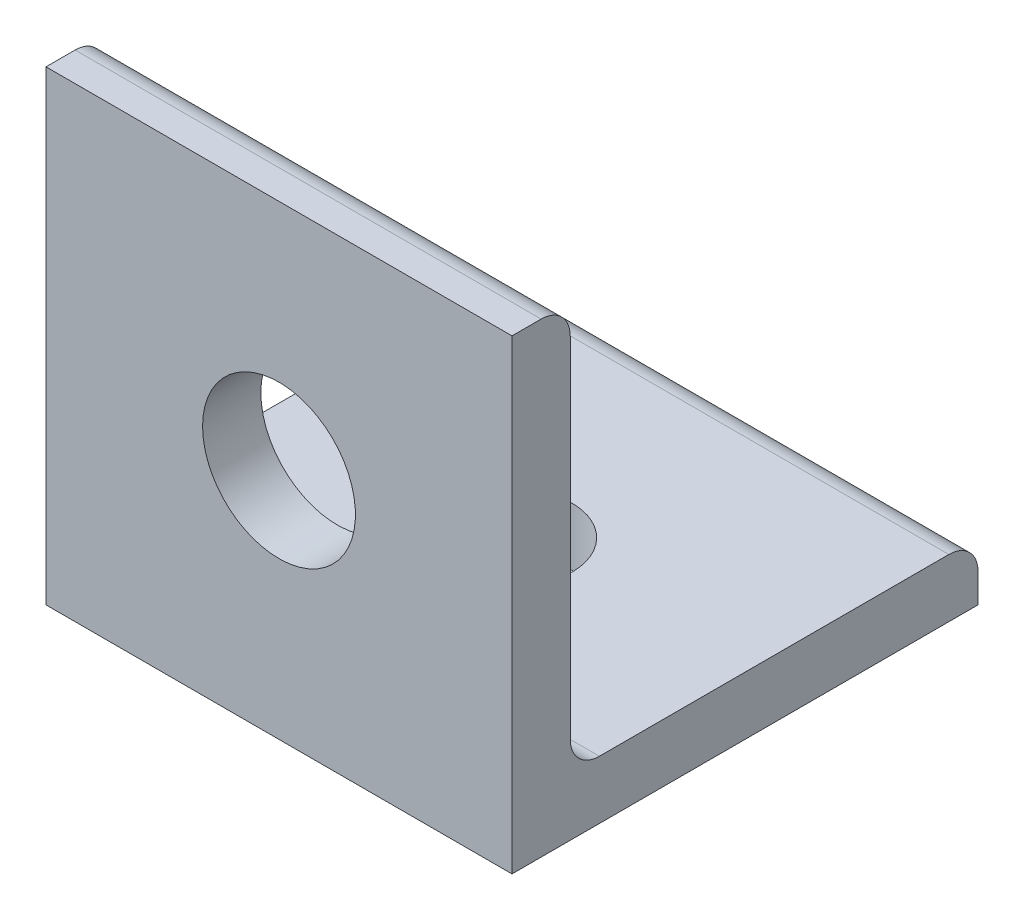
from build123d import *

# Parameters (mm, degrees)
EXTRUDE_THIN1_DEPTH = 12.7
SKETCH2_R           = 4.1656
CUT_EXTRUDE1_DEPTH  = 4.175
SKETCH3_R           = 3.2639
CUT_EXTRUDE2_DEPTH  = 4.175
FILLET1_R           = 1.5875


with BuildPart() as part:
    # Sketch1 → Extrude-Thin1 (new body, symmetric)
    with BuildSketch(Plane(origin=(0, 0, 0), x_dir=(0, 0, -1), z_dir=(1, 0, 0))):
        Polygon((25.4, 0), (0, 0), (0, 25.4), (3.175, 25.4), (3.175, 3.175), (25.4, 3.175), align=None)
    extrude(amount=EXTRUDE_THIN1_DEPTH, both=True)

    # Sketch2 → Cut-Extrude1 (cut, through all)
    with BuildSketch(Plane(origin=(0, 0, -3.175), x_dir=(-1, 0, 0), z_dir=(0, 0, -1))):
        with Locations((0, 12.7)):
            Circle(SKETCH2_R)
    extrude(amount=-CUT_EXTRUDE1_DEPTH, mode=Mode.SUBTRACT)

    # Sketch3 → Cut-Extrude2 (cut, through all)
    with BuildSketch(Plane(origin=(0, 3.175, 0), x_dir=(1, 0, 0), z_dir=(0, 1, 0))):
        with Locations(Location((0, 12.7, 0), (0, 0, 270))):  # turned: the seam where the file's is
            Circle(SKETCH3_R)
    extrude(amount=-CUT_EXTRUDE2_DEPTH, mode=Mode.SUBTRACT)

    # Fillet1
    fillet1_edges = [part.edges().sort_by_distance(p)[0] for p in [
        (0, 25.4, -3.175),
        (0, 3.175, -3.175),
        (0, 3.175, -25.4),
    ]]
    fillet(fillet1_edges, radius=FILLET1_R)


solid = part.part
